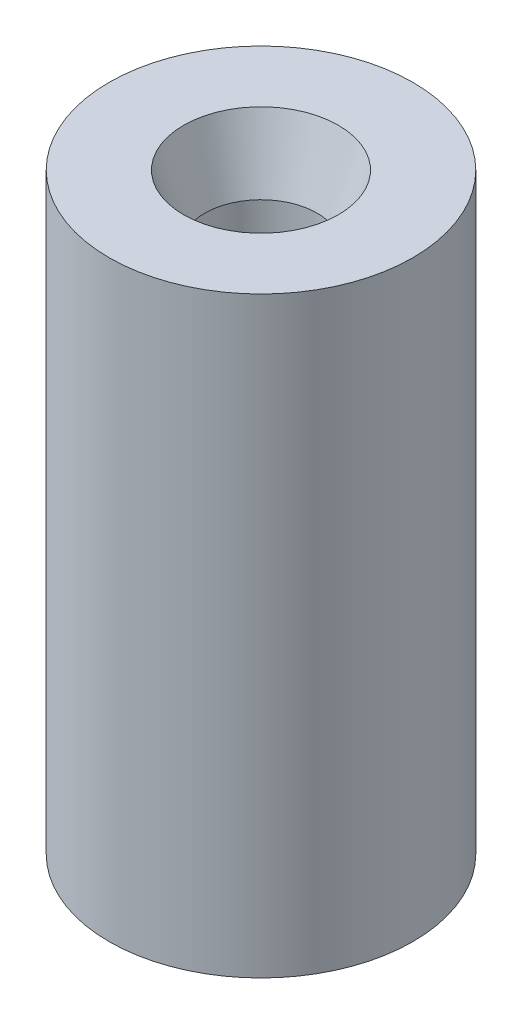
from build123d import *

# Parameters (mm, degrees)
SKETCH1_R             = 5
BOSS_EXTRUDE1_DEPTH   = 19.5
SKETCH2_R             = 1.85
CUT_EXTRUDE1_DEPTH    = 26.5
CHAMFER1_SIZE         = 0.7
CHAMFER1_SIZE2        = 2.154378476
CHAMFER1_PART_2_SIZE  = 0.7
CHAMFER1_PART_2_SIZE2 = 2.154378476


with BuildPart() as part:
    # Sketch1 → Boss-Extrude1 (new body)
    with BuildSketch(Plane(origin=(0, 0, 0), x_dir=(1, 0, 0), z_dir=(0, 1, 0))):
        Circle(SKETCH1_R)
    extrude(amount=BOSS_EXTRUDE1_DEPTH)

    # Sketch2 → Cut-Extrude1 (cut)
    with BuildSketch(Plane(origin=(0, 19.5, 0), x_dir=(1, 0, 0), z_dir=(0, 1, 0))):
        Circle(SKETCH2_R)
    extrude(amount=-CUT_EXTRUDE1_DEPTH, mode=Mode.SUBTRACT)

    # Chamfer1
    chamfer1_edges = [part.edges().sort_by_distance(p)[0] for p in [
        (-1.85, 0, 0),
    ]]
    chamfer1_side = [part.faces().sort_by_distance(p)[0] for p in [
        (-4.858578644, 0, 0),
    ]]
    chamfer(chamfer1_edges, length=CHAMFER1_SIZE, length2=CHAMFER1_SIZE2, reference=chamfer1_side[0])

    # Chamfer1 part 2
    chamfer1_part_2_edges = [part.edges().sort_by_distance(p)[0] for p in [
        (-1.85, 19.5, 0),
    ]]
    chamfer1_part_2_side = [part.faces().sort_by_distance(p)[0] for p in [
        (-4.858578644, 19.5, 0),
    ]]
    chamfer(chamfer1_part_2_edges, length=CHAMFER1_PART_2_SIZE, length2=CHAMFER1_PART_2_SIZE2, reference=chamfer1_part_2_side[0])


solid = part.part
